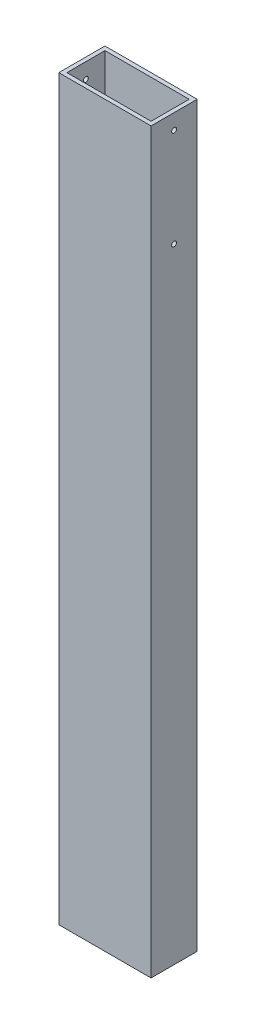
from build123d import *

# Parameters (mm, degrees)
SKETCH1_W           = 38.1
SKETCH1_H           = 19.05
SKETCH1_W_2         = 34.798
SKETCH1_H_2         = 15.748
BOSS_EXTRUDE1_DEPTH = 304.8
SKETCH2_R           = 1.016
CUT_EXTRUDE1_DEPTH  = 39.1


with BuildPart() as part:
    # Sketch1 → Boss-Extrude1 (new body)
    with BuildSketch(Plane(origin=(0, 0, 0), x_dir=(1, 0, 0), z_dir=(0, 1, 0))):
        Rectangle(SKETCH1_W, SKETCH1_H)
        Rectangle(SKETCH1_W_2, SKETCH1_H_2, mode=Mode.SUBTRACT)
    extrude(amount=BOSS_EXTRUDE1_DEPTH)

    # Sketch2 → Cut-Extrude1 (cut, through all)
    with BuildSketch(Plane(origin=(19.05, 0, 0), x_dir=(0, 0, -1), z_dir=(1, 0, 0))):
        with Locations((0, 298.45)):
            Circle(SKETCH2_R)
        with Locations((0, 257.81)):
            Circle(SKETCH2_R)
    extrude(amount=-CUT_EXTRUDE1_DEPTH, mode=Mode.SUBTRACT)


solid = part.part
